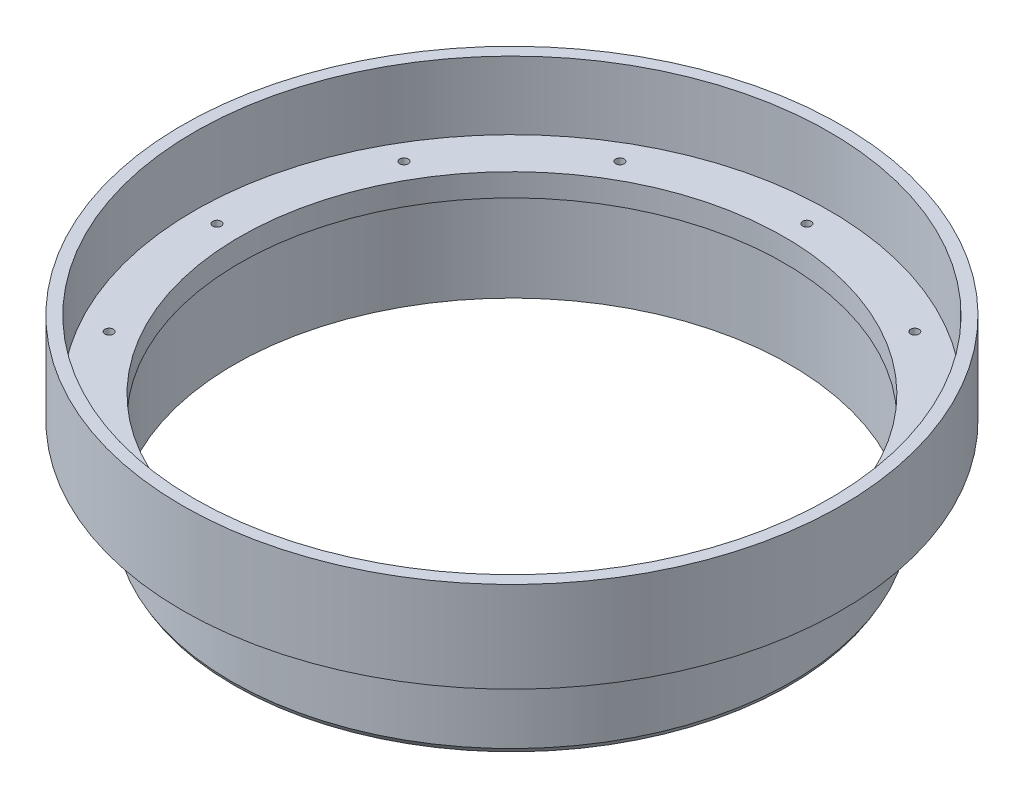
from build123d import *

# Parameters (mm, degrees)
SCREW_HOLES_COUNT = 12


with BuildPart() as part:
    # Cross Section → Main (revolve)
    with BuildSketch(Plane.XY):
        Polygon((-38.1, 0), (-38.1, -3.175), (-38.8874, -3.175), (-38.8874, -15.875), (-39.2684, -15.215088642), (-39.2684, -3.175), (-46.1264, -3.175), (-46.1264, 9.525), (-44.45, 9.525), (-44.45, 0), align=None)
    revolve(axis=Axis((0, 55, 0), (0, -1, 0)))

    # Sketch7 → #0-80 Tapped Hole1 (revolve, cut)
    with BuildSketch(Plane(origin=(-41.275, 0, 0), x_dir=(0, 0, 1), z_dir=(1, 0, 0))):
        Polygon((0, 0), (0, 3.532890611), (0.59563, 3.175), (0.59563, 0), align=None)
    f_0_80_tapped_hole1 = revolve(axis=Axis((-41.275, 6.35, 0), (0, -1, 0)), mode=Mode.SUBTRACT)

    # Screw Holes: #0-80 Tapped Hole1 ×12 about axis
    screw_holes_axis = Axis((0, 0, 0), (0, 1, 0))
    for i in range(1, SCREW_HOLES_COUNT):
        add(f_0_80_tapped_hole1.rotate(screw_holes_axis, i * 360 / SCREW_HOLES_COUNT), mode=Mode.SUBTRACT)


solid = part.part
